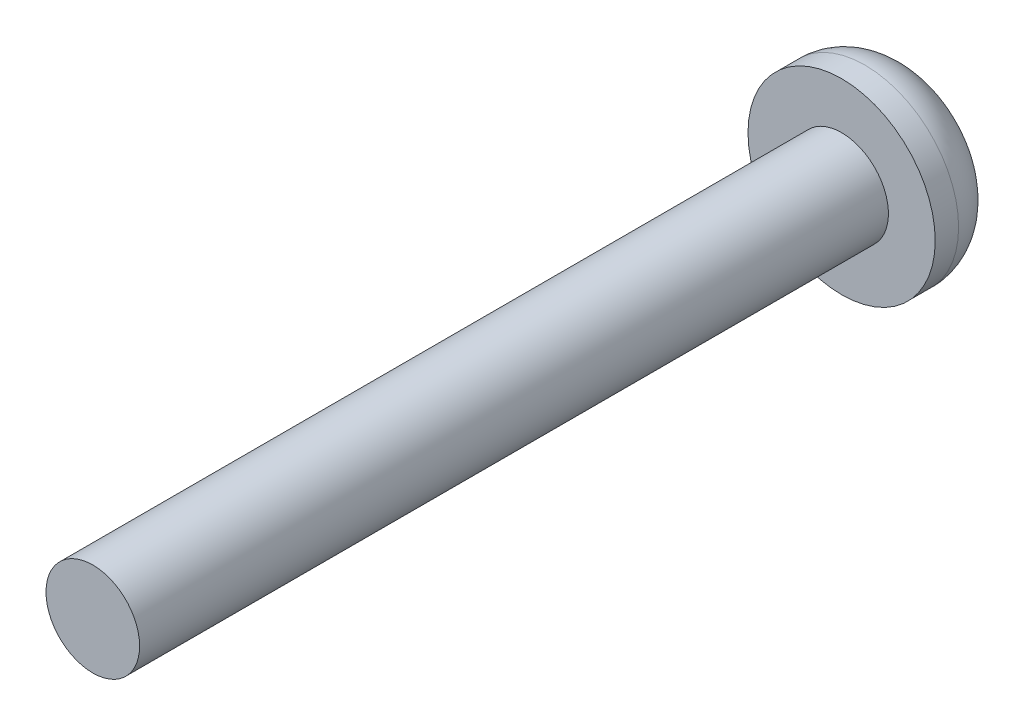
from build123d import *

# Parameters (mm, degrees)
SKETCH1_R           = 1
BOSS_EXTRUDE1_DEPTH = 16
SKETCH2_R           = 2
BOSS_EXTRUDE2_DEPTH = 1.5
FILLET1_R           = 1


with BuildPart() as part:
    # Sketch1 → Boss-Extrude1 (new body)
    with BuildSketch(Plane.XY):
        Circle(SKETCH1_R)
    extrude(amount=BOSS_EXTRUDE1_DEPTH)

    # Sketch2 → Boss-Extrude2 (add)
    with BuildSketch(Plane(origin=(0, 0, 0), x_dir=(-1, 0, 0), z_dir=(0, 0, -1))):
        Circle(SKETCH2_R)
    extrude(amount=BOSS_EXTRUDE2_DEPTH)

    # Fillet1
    fillet1_edges = [part.edges().sort_by_distance(p)[0] for p in [
        (2, 0, -1.5),
    ]]
    fillet(fillet1_edges, radius=FILLET1_R)


solid = part.part
